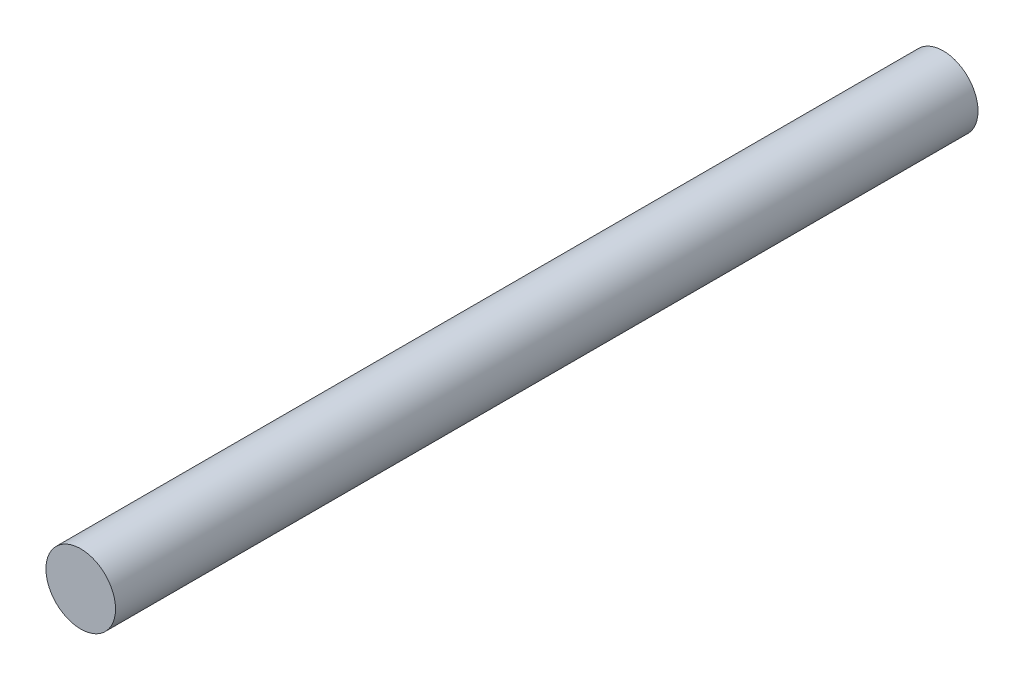
from build123d import *

# Parameters (mm, degrees)
SKETCH1_R           = 2.413
BOSS_EXTRUDE1_DEPTH = 59.817


with BuildPart() as part:
    # Sketch1 → Boss-Extrude1 (new body)
    with BuildSketch(Plane.XY):
        Circle(SKETCH1_R)
    extrude(amount=BOSS_EXTRUDE1_DEPTH)


solid = part.part
